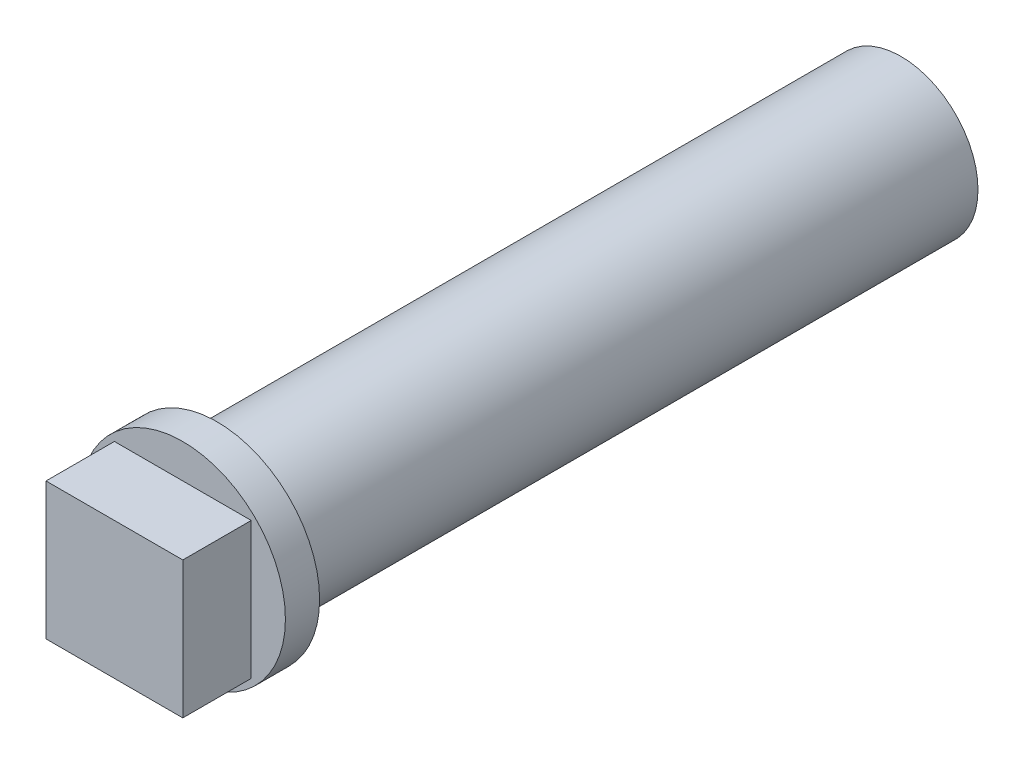
from build123d import *

# Parameters (mm, degrees)
SKETCH_1_R          = 2.25
EXTRUDE_2_DEPTH     = 20
SKETCH_7_W          = 2.4
SKETCH_7_H          = 2.4
CUT_EXTRUDE_3_DEPTH = 2.5
SKETCH_9_R          = 3
EXTRUDE_4_DEPTH     = 1
SKETCH_10_W         = 4
SKETCH_10_H         = 4
EXTRUDE_5_DEPTH     = 2


with BuildPart() as part:
    # 草图1 → 凸台-拉伸2 (new body)
    with BuildSketch(Plane.XY):
        Circle(SKETCH_1_R)
    extrude(amount=EXTRUDE_2_DEPTH)

    # 草图7 → 切除-拉伸3 (cut)
    with BuildSketch(Plane.XY):
        Rectangle(SKETCH_7_W, SKETCH_7_H)
    extrude(amount=CUT_EXTRUDE_3_DEPTH, mode=Mode.SUBTRACT)

    # 草图9 → 凸台-拉伸4 (add)
    with BuildSketch(Plane.XY.offset(20)):
        Circle(SKETCH_9_R)
    extrude(amount=EXTRUDE_4_DEPTH)

    # 草图10 → 凸台-拉伸5 (add)
    with BuildSketch(Plane.XY.offset(21)):
        Rectangle(SKETCH_10_W, SKETCH_10_H)
    extrude(amount=EXTRUDE_5_DEPTH)


solid = part.part
